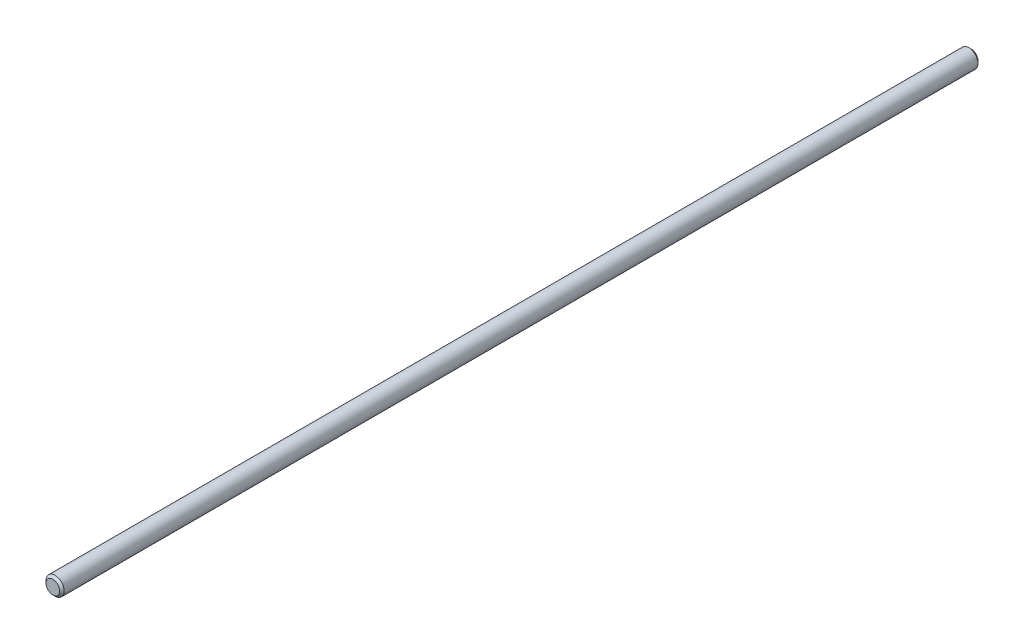
from build123d import *

# Parameters (mm, degrees)
SKETCH1_R           = 4
BOSS_EXTRUDE1_DEPTH = 405
CHAMFER2_SIZE       = 1
CHAMFER3_SIZE       = 1


with BuildPart() as part:
    # Sketch1 → Boss-Extrude1 (new body)
    with BuildSketch(Plane.XY):
        Circle(SKETCH1_R)
    extrude(amount=BOSS_EXTRUDE1_DEPTH)

    # Chamfer2
    chamfer2_edges = [part.edges().sort_by_distance(p)[0] for p in [
        (-4, 0, 0),
    ]]
    chamfer(chamfer2_edges, length=CHAMFER2_SIZE)

    # Chamfer3
    chamfer3_edges = [part.edges().sort_by_distance(p)[0] for p in [
        (-4, 0, 405),
    ]]
    chamfer(chamfer3_edges, length=CHAMFER3_SIZE)


solid = part.part
